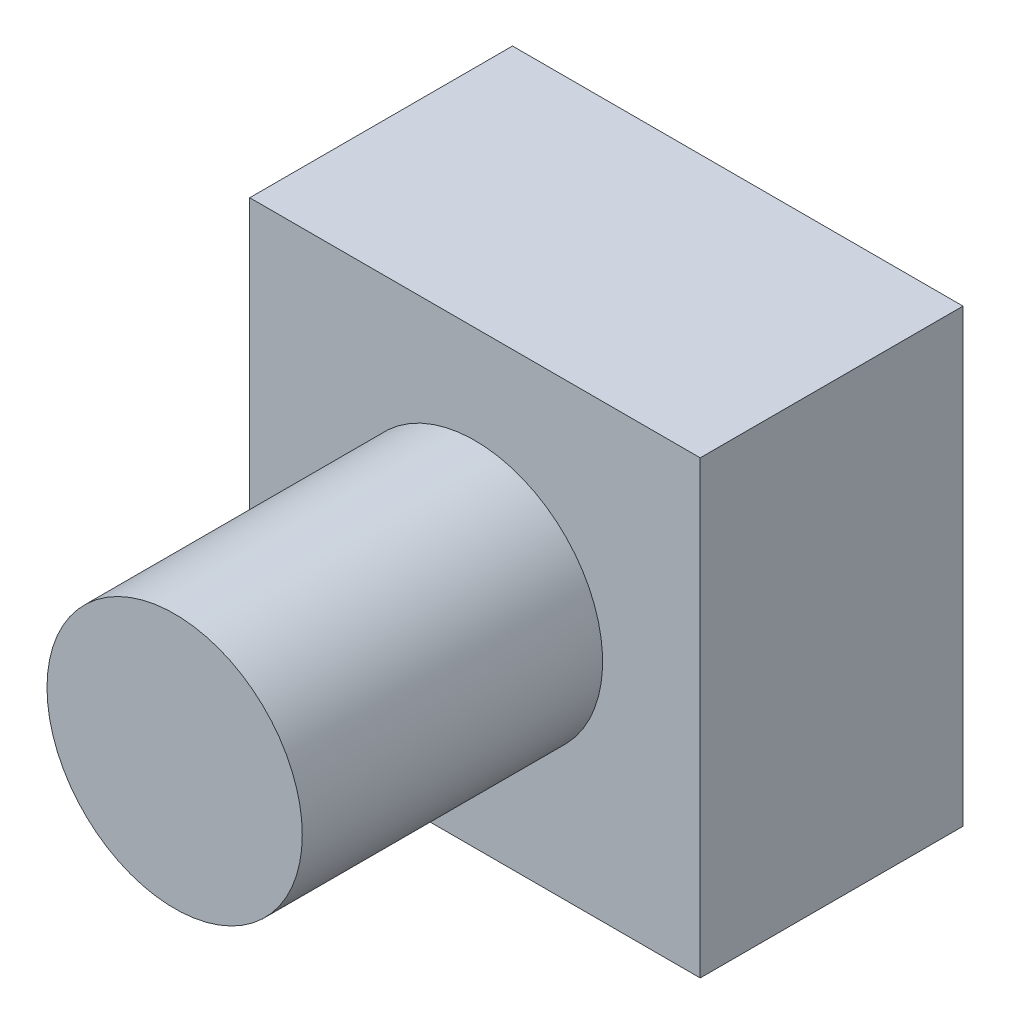
from build123d import *

# Parameters (mm, degrees)
SKETCH1_W           = 6
SKETCH1_H           = 6
BOSS_EXTRUDE1_DEPTH = 3.5
SKETCH2_R           = 1.7
BOSS_EXTRUDE2_DEPTH = 4


with BuildPart() as part:
    # Sketch1 → Boss-Extrude1 (new body)
    with BuildSketch(Plane.XY):
        with Locations((3, 3)):
            Rectangle(SKETCH1_W, SKETCH1_H)
    extrude(amount=BOSS_EXTRUDE1_DEPTH)

    # Sketch2 → Boss-Extrude2 (add)
    with BuildSketch(Plane.XY.offset(3.5)):
        with Locations((3, 3)):
            Circle(SKETCH2_R)
    extrude(amount=BOSS_EXTRUDE2_DEPTH)


solid = part.part
